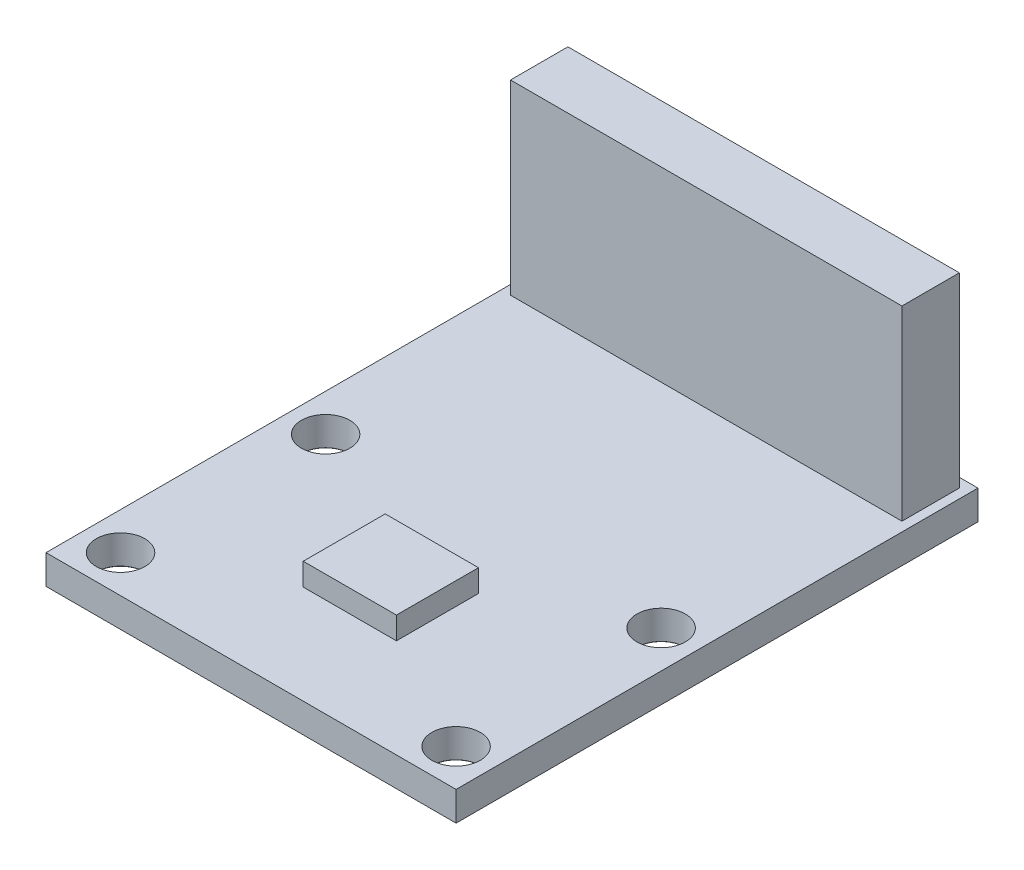
from build123d import *

# Parameters (mm, degrees)
SKETCH1_W                           = 22
SKETCH1_H                           = 28
BOSS_EXTRUDE1_DEPTH                 = 1.57
F_2_6_2_6_DIAMETER_HOLE1_AT_2_COUNT = 2
F_2_6_2_6_DIAMETER_HOLE1_AT_2_PITCH = 11
F_2_6_2_6_DIAMETER_HOLE1_AT_3_COUNT = 2
F_2_6_2_6_DIAMETER_HOLE1_AT_3_PITCH = 21.09502311
F_2_6_2_6_DIAMETER_HOLE1_AT_4_COUNT = 2
F_2_6_2_6_DIAMETER_HOLE1_AT_4_PITCH = 18
SKETCH5_W                           = 5
SKETCH5_H                           = 4.4
BOSS_EXTRUDE2_DEPTH                 = 1.2
SKETCH6_W                           = 21
SKETCH6_H                           = 3.08
BOSS_EXTRUDE3_DEPTH                 = 10


with BuildPart() as part:
    # Sketch1 → Boss-Extrude1 (new body)
    with BuildSketch(Plane(origin=(0, 0, 0), x_dir=(1, 0, 0), z_dir=(0, 1, 0))):
        with Locations((0, 6.5)):
            Rectangle(SKETCH1_W, SKETCH1_H)
    extrude(amount=BOSS_EXTRUDE1_DEPTH)

    # Sketch3 → Ø2.6 (2.6) Diameter Hole1 (revolve, cut)
    with BuildSketch(Plane(origin=(-9, 1.57, -5.5), x_dir=(0, 0, 1), z_dir=(1, 0, 0))):
        Polygon((0, 0), (0, 1.57), (1.325, 1.57), (1.3, 1.545), (1.3, 0), align=None)
    f_2_6_2_6_diameter_hole1 = revolve(axis=Axis((-9, 7.92, -5.5), (0, -1, 0)), mode=Mode.SUBTRACT)

    # Ø2.6 (2.6) Diameter Hole1 at 2: Ø2.6 (2.6) Diameter Hole1 ×2
    with Locations(*[(0, 0, i * F_2_6_2_6_DIAMETER_HOLE1_AT_2_PITCH) for i in range(1, F_2_6_2_6_DIAMETER_HOLE1_AT_2_COUNT)]):
        add(f_2_6_2_6_diameter_hole1, mode=Mode.SUBTRACT)

    # Ø2.6 (2.6) Diameter Hole1 at 3: Ø2.6 (2.6) Diameter Hole1 ×2
    with Locations(*[Vector(0.853281834, 0, 0.521450009) * (i * F_2_6_2_6_DIAMETER_HOLE1_AT_3_PITCH) for i in range(1, F_2_6_2_6_DIAMETER_HOLE1_AT_3_COUNT)]):
        add(f_2_6_2_6_diameter_hole1, mode=Mode.SUBTRACT)

    # Ø2.6 (2.6) Diameter Hole1 at 4: Ø2.6 (2.6) Diameter Hole1 ×2
    with Locations(*[(i * F_2_6_2_6_DIAMETER_HOLE1_AT_4_PITCH, 0, 0) for i in range(1, F_2_6_2_6_DIAMETER_HOLE1_AT_4_COUNT)]):
        add(f_2_6_2_6_diameter_hole1, mode=Mode.SUBTRACT)

    # Sketch5 → Boss-Extrude2 (add)
    with BuildSketch(Plane(origin=(0, 1.57, 0), x_dir=(1, 0, 0), z_dir=(0, 1, 0))):
        Rectangle(SKETCH5_W, SKETCH5_H)
    extrude(amount=BOSS_EXTRUDE2_DEPTH)

    # Sketch6 → Boss-Extrude3 (add)
    with BuildSketch(Plane(origin=(0, 1.57, 0), x_dir=(1, 0, 0), z_dir=(0, 1, 0))):
        with Locations((0, 18.46)):
            Rectangle(SKETCH6_W, SKETCH6_H)
    extrude(amount=BOSS_EXTRUDE3_DEPTH)


solid = part.part
